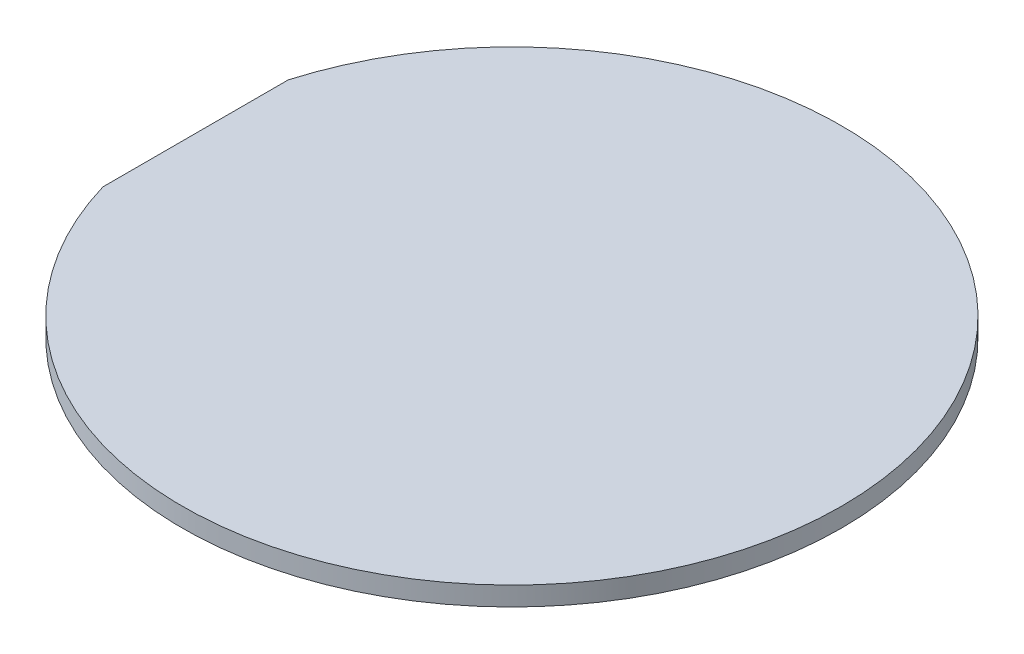
from build123d import *

# Parameters (mm, degrees)
SKETCH_1_R          = 15.9
EXTRUDE_1_DEPTH     = 1
SKETCH_2_R          = 17.35
EXTRUDE_2_DEPTH     = 1
CUT_EXTRUDE_1_DEPTH = 1


with BuildPart() as part:
    # 草图1 → 凸台-拉伸1 (new body)
    with BuildSketch(Plane(origin=(0, 0, 0), x_dir=(1, 0, 0), z_dir=(0, 1, 0))):
        Circle(SKETCH_1_R)
    extrude(amount=EXTRUDE_1_DEPTH)

    # 草图2 → 凸台-拉伸2 (add)
    with BuildSketch(Plane(origin=(0, 1, 0), x_dir=(1, 0, 0), z_dir=(0, 1, 0))):
        Circle(SKETCH_2_R)
    extrude(amount=EXTRUDE_2_DEPTH)

    # 草图3 → 切除-拉伸1 (cut)
    with BuildSketch(Plane.XZ.offset(-1)):
        with BuildLine():
            Line((-16.65, 4.878524367), (-16.65, -4.878524367))
            ThreePointArc((-16.65, -4.878524367), (-17.35, 0), (-16.65, 4.878524367))
        make_face()
    extrude(amount=-CUT_EXTRUDE_1_DEPTH, mode=Mode.SUBTRACT)


solid = part.part
